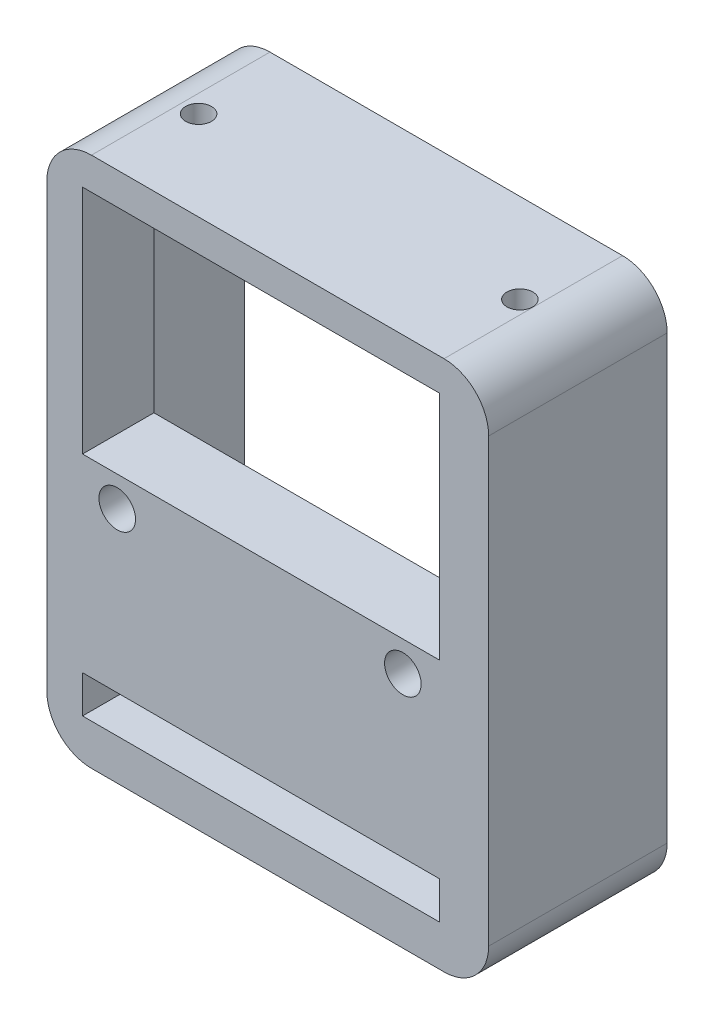
from build123d import *

# Parameters (mm, degrees)
EXTRUDE_1_DEPTH     = 20
SKETCH_2_W          = 45.2
SKETCH_2_H          = 55.2
CUT_EXTRUDE_1_DEPTH = 12
SKETCH_4_W          = 40
SKETCH_4_H          = 25.9
SKETCH_4_H_2        = 4.2
CUT_EXTRUDE_2_DEPTH = 44.561737798
SKETCH_6_R          = 1.45
CUT_EXTRUDE_4_DEPTH = 41.516971753
SKETCH_7_R          = 2.05
CUT_EXTRUDE_5_DEPTH = 6
SKETCH_8_R          = 1.45
CUT_EXTRUDE_6_DEPTH = 6
SKETCH_9_R          = 1.45
CUT_EXTRUDE_7_DEPTH = 6


with BuildPart() as part:
    # 草图1 → 凸台-拉伸1 (new body)
    with BuildSketch(Plane.XY):
        with BuildLine():
            Line((-19.75, 29.75), (19.75, 29.75))
            ThreePointArc((19.75, 29.75), (23.285533906, 28.285533906), (24.75, 24.75))
            Line((24.75, 24.75), (24.75, -24.75))
            ThreePointArc((24.75, -24.75), (23.285533906, -28.285533906), (19.75, -29.75))
            Line((19.75, -29.75), (-19.75, -29.75))
            ThreePointArc((-19.75, -29.75), (-23.285533906, -28.285533906), (-24.75, -24.75))
            Line((-24.75, -24.75), (-24.75, 24.75))
            ThreePointArc((-24.75, 24.75), (-23.285533906, 28.285533906), (-19.75, 29.75))
        make_face()
    extrude(amount=EXTRUDE_1_DEPTH)

    # 草图2 → 切除-拉伸1 (cut)
    with BuildSketch(Plane(origin=(0, 0, 0), x_dir=(-1, 0, 0), z_dir=(0, 0, -1))):
        Rectangle(SKETCH_2_W, SKETCH_2_H)
    extrude(amount=-CUT_EXTRUDE_1_DEPTH, mode=Mode.SUBTRACT)

    # 草图4 → 切除-拉伸2 (cut, through all)
    with BuildSketch(Plane.XY.offset(20)):
        with Locations((-0.75, 13.2)):
            Rectangle(SKETCH_4_W, SKETCH_4_H)
        with Locations((-0.75, -23.065049662)):
            Rectangle(SKETCH_4_W, SKETCH_4_H_2)
    extrude(amount=-CUT_EXTRUDE_2_DEPTH, mode=Mode.SUBTRACT)

    # 草图6 → 切除-拉伸4 (cut, through all)
    with BuildSketch(Plane(origin=(0, 0, 12), x_dir=(-1, 0, 0), z_dir=(0, 0, -1))):
        with Locations((16.862, -3.116)):
            Circle(SKETCH_6_R)
        with Locations((-15.138, -3.116)):
            Circle(SKETCH_6_R)
    extrude(amount=-CUT_EXTRUDE_4_DEPTH, mode=Mode.SUBTRACT)

    # 草图7 → 切除-拉伸5 (cut)
    with BuildSketch(Plane.XY.offset(20)):
        with Locations((-16.862, -3.116)):
            Circle(SKETCH_7_R)
        with Locations((15.138, -3.116)):
            Circle(SKETCH_7_R)
    extrude(amount=-CUT_EXTRUDE_5_DEPTH, mode=Mode.SUBTRACT)

    # 草图8 → 切除-拉伸6 (cut)
    with BuildSketch(Plane(origin=(0, 29.75, 0), x_dir=(1, 0, 0), z_dir=(0, 1, 0))):
        with Locations((-17.75, -10)):
            Circle(SKETCH_8_R)
        with Locations((18.25, -10)):
            Circle(SKETCH_8_R)
    extrude(amount=-CUT_EXTRUDE_6_DEPTH, mode=Mode.SUBTRACT)

    # 草图9 → 切除-拉伸7 (cut)
    with BuildSketch(Plane.XZ.offset(29.75)):
        with Locations((-10, 10)):
            Circle(SKETCH_9_R)
        with Locations((10, 10)):
            Circle(SKETCH_9_R)
    extrude(amount=-CUT_EXTRUDE_7_DEPTH, mode=Mode.SUBTRACT)


solid = part.part
